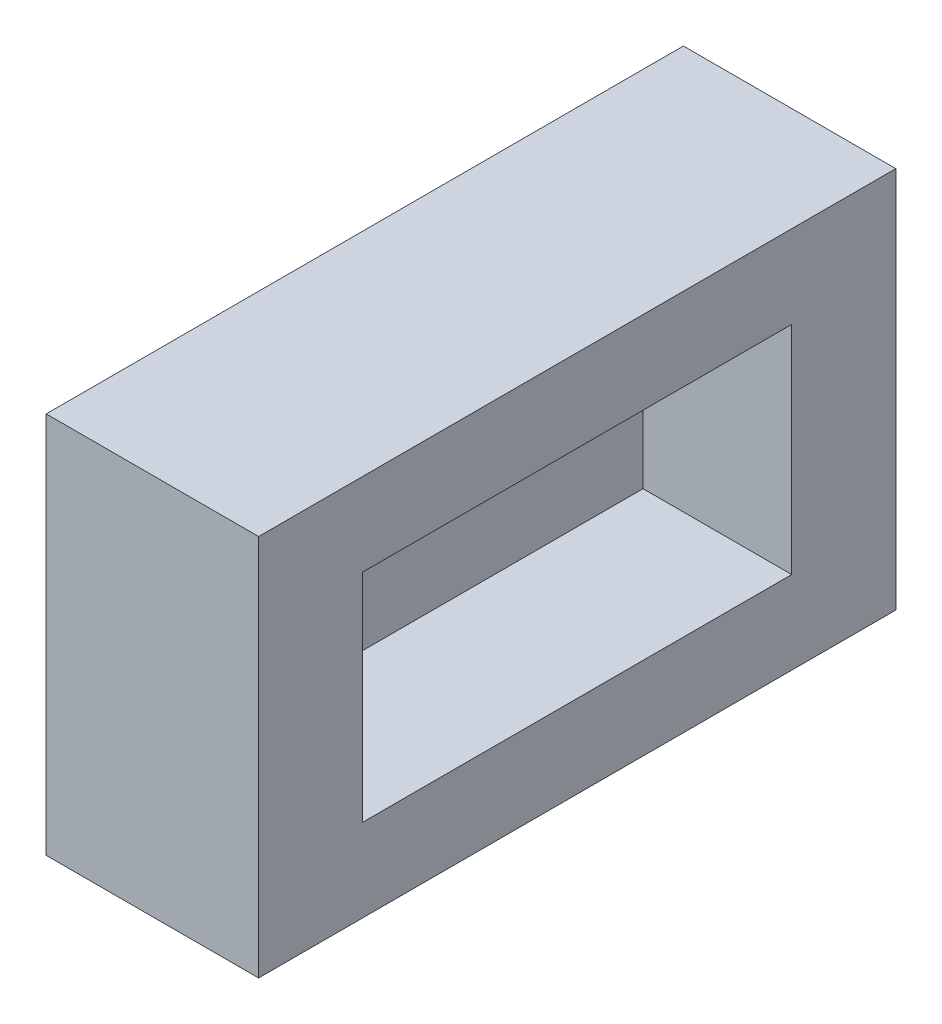
from build123d import *

# Parameters (mm, degrees)
SKETCH1_W           = 10
SKETCH1_H           = 30
BOSS_EXTRUDE1_DEPTH = 18
SKETCH2_W           = 20.2
SKETCH2_H           = 10.2
CUT_EXTRUDE1_DEPTH  = 7


with BuildPart() as part:
    # Sketch1 → Boss-Extrude1 (new body)
    with BuildSketch(Plane(origin=(0, 0, 0), x_dir=(1, 0, 0), z_dir=(0, 1, 0))):
        Rectangle(SKETCH1_W, SKETCH1_H)
    extrude(amount=BOSS_EXTRUDE1_DEPTH)

    # Sketch2 → Cut-Extrude1 (cut)
    with BuildSketch(Plane(origin=(5, 0, 0), x_dir=(0, 0, -1), z_dir=(1, 0, 0))):
        with Locations((0, 9)):
            Rectangle(SKETCH2_W, SKETCH2_H)
    extrude(amount=-CUT_EXTRUDE1_DEPTH, mode=Mode.SUBTRACT)


solid = part.part
